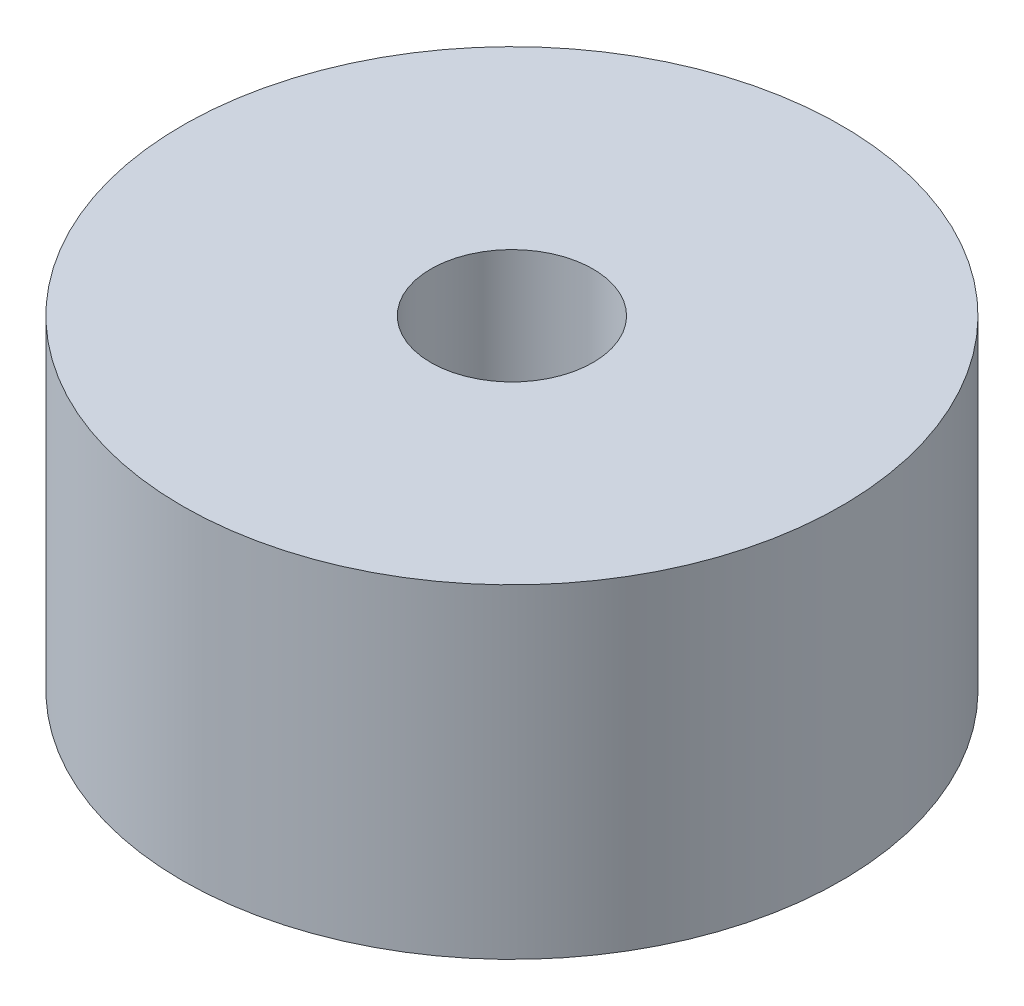
from build123d import *

# Parameters (mm, degrees)
SKETCH1_R           = 6.4516
SKETCH1_R_2         = 1.5875
BOSS_EXTRUDE1_DEPTH = 6.35


with BuildPart() as part:
    # Sketch1 → Boss-Extrude1 (new body)
    with BuildSketch(Plane(origin=(0, 0, 0), x_dir=(1, 0, 0), z_dir=(0, 1, 0))):
        Circle(SKETCH1_R)
        Circle(SKETCH1_R_2, mode=Mode.SUBTRACT)
    extrude(amount=BOSS_EXTRUDE1_DEPTH)


solid = part.part
